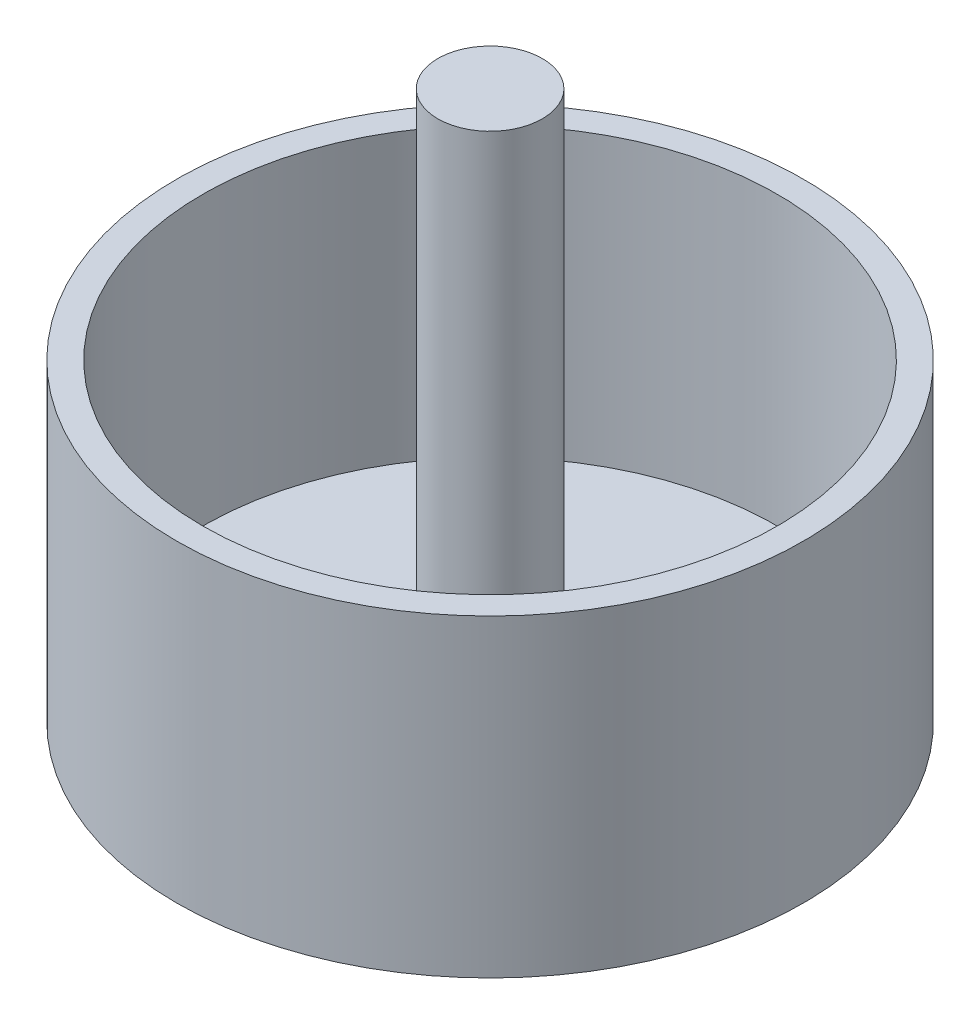
from build123d import *

# Parameters (mm, degrees)
SKETCH1_R           = 76.2
BOSS_EXTRUDE1_DEPTH = 76.2
SKETCH2_R           = 12.7
BOSS_EXTRUDE2_DEPTH = 57.15
SKETCH3_R           = 69.85
SKETCH3_R_2         = 12.7
CUT_EXTRUDE1_DEPTH  = 69.85


with BuildPart() as part:
    # Sketch1 → Boss-Extrude1 (new body)
    with BuildSketch(Plane(origin=(0, 0, 0), x_dir=(1, 0, 0), z_dir=(0, 1, 0))):
        Circle(SKETCH1_R)
    extrude(amount=BOSS_EXTRUDE1_DEPTH)

    # Sketch2 → Boss-Extrude2 (add)
    with BuildSketch(Plane(origin=(0, 76.2, 0), x_dir=(1, 0, 0), z_dir=(0, 1, 0))):
        Circle(SKETCH2_R)
    extrude(amount=BOSS_EXTRUDE2_DEPTH)

    # Sketch3 → Cut-Extrude1 (cut)
    with BuildSketch(Plane(origin=(0, 76.2, 0), x_dir=(1, 0, 0), z_dir=(0, 1, 0))):
        Circle(SKETCH3_R)
        Circle(SKETCH3_R_2, mode=Mode.SUBTRACT)
    extrude(amount=-CUT_EXTRUDE1_DEPTH, mode=Mode.SUBTRACT)


solid = part.part
